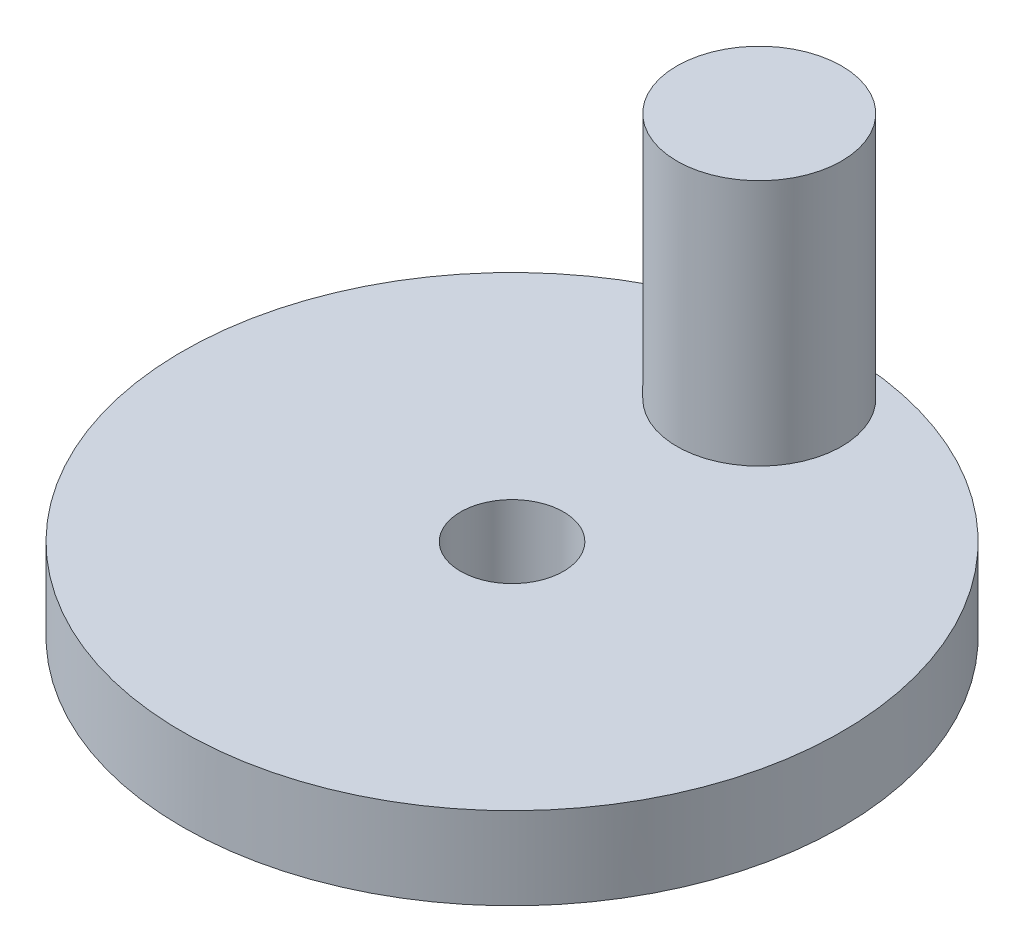
from build123d import *

# Parameters (mm, degrees)
SKETCH_1_R      = 8
SKETCH_1_R_2    = 1.25
EXTRUDE_1_DEPTH = 2
SKETCH_3_R      = 2
EXTRUDE_2_DEPTH = 6


with BuildPart() as part:
    # 草图1 → 凸台-拉伸1 (new body)
    with BuildSketch(Plane(origin=(0, 0, 0), x_dir=(1, 0, 0), z_dir=(0, 1, 0))):
        Circle(SKETCH_1_R)
        Circle(SKETCH_1_R_2, mode=Mode.SUBTRACT)
    extrude(amount=EXTRUDE_1_DEPTH)

    # 草图3 → 凸台-拉伸2 (add)
    with BuildSketch(Plane(origin=(0, 2, 0), x_dir=(1, 0, 0), z_dir=(0, 1, 0))):
        with Locations((0, 6)):
            Circle(SKETCH_3_R)
    extrude(amount=EXTRUDE_2_DEPTH)


solid = part.part
